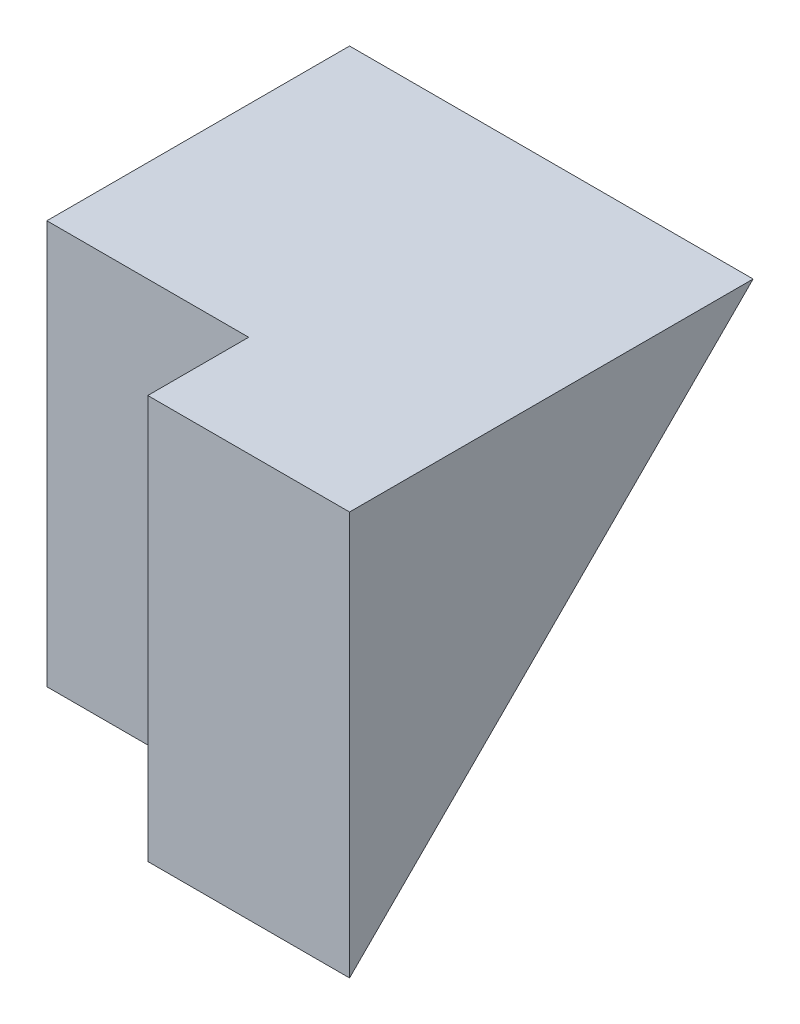
from build123d import *

# Parameters (mm, degrees)
SKETCH1_W           = 4
SKETCH1_H           = 4
BOSS_EXTRUDE1_DEPTH = 2
SKETCH2_W           = 3
SKETCH2_H           = 4
BOSS_EXTRUDE2_DEPTH = 2
CUT_EXTRUDE1_DEPTH  = 2


with BuildPart() as part:
    # Sketch1 → Boss-Extrude1 (new body)
    with BuildSketch(Plane(origin=(0, 0, 0), x_dir=(0, 0, -1), z_dir=(1, 0, 0))):
        with Locations((2, 2)):
            Rectangle(SKETCH1_W, SKETCH1_H)
    extrude(amount=BOSS_EXTRUDE1_DEPTH)

    # Sketch2 → Boss-Extrude2 (add)
    with BuildSketch(Plane.ZY):
        with Locations((-2.5, 2)):
            Rectangle(SKETCH2_W, SKETCH2_H)
    extrude(amount=BOSS_EXTRUDE2_DEPTH)

    # Sketch3 → Cut-Extrude1 (cut)
    with BuildSketch(Plane(origin=(2, 0, 0), x_dir=(0, 0, -1), z_dir=(1, 0, 0))):
        Polygon((0, 0), (4, 4), (4, 0), align=None)
    extrude(amount=-CUT_EXTRUDE1_DEPTH, mode=Mode.SUBTRACT)


solid = part.part
